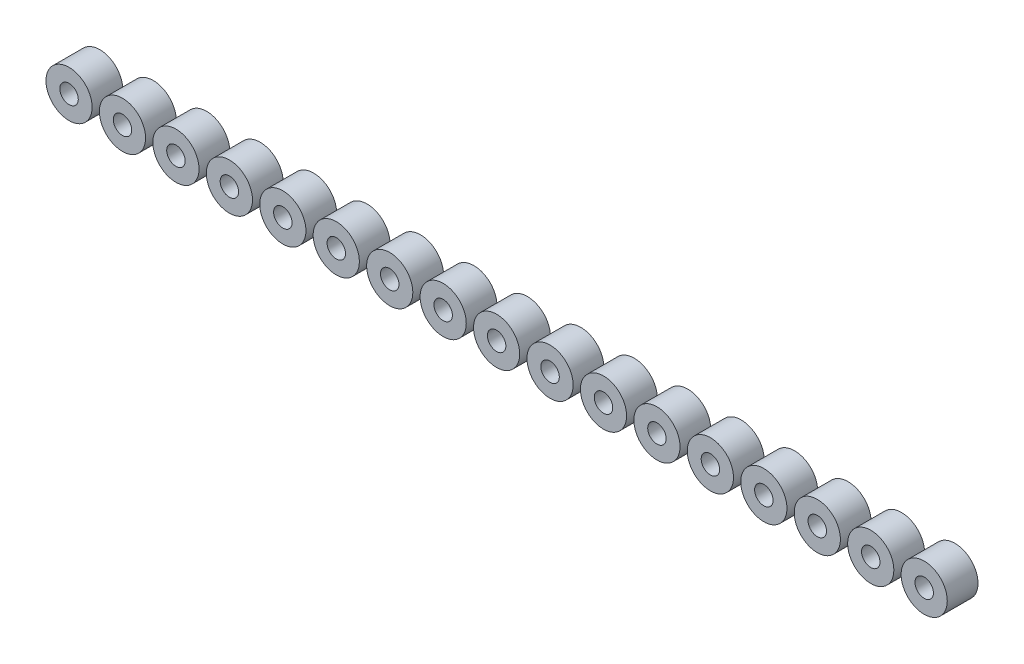
from build123d import *

# Parameters (mm, degrees)
SZKIC1_R                       = 953
SZKIC1_R_2                     = 381
DODANIE_WYCI_GNI_CIE1_DEPTH    = 1268
DODANIE_WYCI_GNI_CIE1_2_DEPTH  = 1268
DODANIE_WYCI_GNI_CIE1_3_DEPTH  = 1268
DODANIE_WYCI_GNI_CIE1_4_DEPTH  = 1268
DODANIE_WYCI_GNI_CIE1_5_DEPTH  = 1268
DODANIE_WYCI_GNI_CIE1_6_DEPTH  = 1268
DODANIE_WYCI_GNI_CIE1_7_DEPTH  = 1268
DODANIE_WYCI_GNI_CIE1_8_DEPTH  = 1268
DODANIE_WYCI_GNI_CIE1_9_DEPTH  = 1268
DODANIE_WYCI_GNI_CIE1_10_DEPTH = 1268
DODANIE_WYCI_GNI_CIE1_11_DEPTH = 1268
DODANIE_WYCI_GNI_CIE1_12_DEPTH = 1268
DODANIE_WYCI_GNI_CIE1_13_DEPTH = 1268
DODANIE_WYCI_GNI_CIE1_14_DEPTH = 1268
DODANIE_WYCI_GNI_CIE1_15_DEPTH = 1268
DODANIE_WYCI_GNI_CIE1_16_DEPTH = 1268
DODANIE_WYCI_GNI_CIE1_17_DEPTH = 1268


with BuildPart() as part:
    # Szkic1 → Dodanie-wyciągnięcie1 (new body)
    with BuildSketch(Plane.XY):
        Circle(SZKIC1_R)
        Circle(SZKIC1_R_2, mode=Mode.SUBTRACT)
    extrude(amount=DODANIE_WYCI_GNI_CIE1_DEPTH)


with BuildPart() as body_2:
    # Szkic1 → Dodanie-wyci_gni_cie1 2 (new body)
    with BuildSketch(Plane.XY):
        with Locations((2206, 0)):
            Circle(SZKIC1_R)
        with Locations((2206, 0)):
            Circle(SZKIC1_R_2, mode=Mode.SUBTRACT)
    extrude(amount=DODANIE_WYCI_GNI_CIE1_2_DEPTH)


with BuildPart() as body_3:
    # Szkic1 → Dodanie-wyci_gni_cie1 3 (new body)
    with BuildSketch(Plane.XY):
        with Locations((4412, 0)):
            Circle(SZKIC1_R)
        with Locations((4412, 0)):
            Circle(SZKIC1_R_2, mode=Mode.SUBTRACT)
    extrude(amount=DODANIE_WYCI_GNI_CIE1_3_DEPTH)


with BuildPart() as body_4:
    # Szkic1 → Dodanie-wyci_gni_cie1 4 (new body)
    with BuildSketch(Plane.XY):
        with Locations((6618, 0)):
            Circle(SZKIC1_R)
        with Locations((6618, 0)):
            Circle(SZKIC1_R_2, mode=Mode.SUBTRACT)
    extrude(amount=DODANIE_WYCI_GNI_CIE1_4_DEPTH)


with BuildPart() as body_5:
    # Szkic1 → Dodanie-wyci_gni_cie1 5 (new body)
    with BuildSketch(Plane.XY):
        with Locations((8824, 0)):
            Circle(SZKIC1_R)
        with Locations((8824, 0)):
            Circle(SZKIC1_R_2, mode=Mode.SUBTRACT)
    extrude(amount=DODANIE_WYCI_GNI_CIE1_5_DEPTH)


with BuildPart() as body_6:
    # Szkic1 → Dodanie-wyci_gni_cie1 6 (new body)
    with BuildSketch(Plane.XY):
        with Locations((11030, 0)):
            Circle(SZKIC1_R)
        with Locations((11030, 0)):
            Circle(SZKIC1_R_2, mode=Mode.SUBTRACT)
    extrude(amount=DODANIE_WYCI_GNI_CIE1_6_DEPTH)


with BuildPart() as body_7:
    # Szkic1 → Dodanie-wyci_gni_cie1 7 (new body)
    with BuildSketch(Plane.XY):
        with Locations((13236, 0)):
            Circle(SZKIC1_R)
        with Locations((13236, 0)):
            Circle(SZKIC1_R_2, mode=Mode.SUBTRACT)
    extrude(amount=DODANIE_WYCI_GNI_CIE1_7_DEPTH)


with BuildPart() as body_8:
    # Szkic1 → Dodanie-wyci_gni_cie1 8 (new body)
    with BuildSketch(Plane.XY):
        with Locations((15442, 0)):
            Circle(SZKIC1_R)
        with Locations((15442, 0)):
            Circle(SZKIC1_R_2, mode=Mode.SUBTRACT)
    extrude(amount=DODANIE_WYCI_GNI_CIE1_8_DEPTH)


with BuildPart() as body_9:
    # Szkic1 → Dodanie-wyci_gni_cie1 9 (new body)
    with BuildSketch(Plane.XY):
        with Locations((17648, 0)):
            Circle(SZKIC1_R)
        with Locations((17648, 0)):
            Circle(SZKIC1_R_2, mode=Mode.SUBTRACT)
    extrude(amount=DODANIE_WYCI_GNI_CIE1_9_DEPTH)


with BuildPart() as body_10:
    # Szkic1 → Dodanie-wyci_gni_cie1 10 (new body)
    with BuildSketch(Plane.XY):
        with Locations((19854, 0)):
            Circle(SZKIC1_R)
        with Locations((19854, 0)):
            Circle(SZKIC1_R_2, mode=Mode.SUBTRACT)
    extrude(amount=DODANIE_WYCI_GNI_CIE1_10_DEPTH)


with BuildPart() as body_11:
    # Szkic1 → Dodanie-wyci_gni_cie1 11 (new body)
    with BuildSketch(Plane.XY):
        with Locations((22060, 0)):
            Circle(SZKIC1_R)
        with Locations((22060, 0)):
            Circle(SZKIC1_R_2, mode=Mode.SUBTRACT)
    extrude(amount=DODANIE_WYCI_GNI_CIE1_11_DEPTH)


with BuildPart() as body_12:
    # Szkic1 → Dodanie-wyci_gni_cie1 12 (new body)
    with BuildSketch(Plane.XY):
        with Locations((24266, 0)):
            Circle(SZKIC1_R)
        with Locations((24266, 0)):
            Circle(SZKIC1_R_2, mode=Mode.SUBTRACT)
    extrude(amount=DODANIE_WYCI_GNI_CIE1_12_DEPTH)


with BuildPart() as body_13:
    # Szkic1 → Dodanie-wyci_gni_cie1 13 (new body)
    with BuildSketch(Plane.XY):
        with Locations((26472, 0)):
            Circle(SZKIC1_R)
        with Locations((26472, 0)):
            Circle(SZKIC1_R_2, mode=Mode.SUBTRACT)
    extrude(amount=DODANIE_WYCI_GNI_CIE1_13_DEPTH)


with BuildPart() as body_14:
    # Szkic1 → Dodanie-wyci_gni_cie1 14 (new body)
    with BuildSketch(Plane.XY):
        with Locations((28678, 0)):
            Circle(SZKIC1_R)
        with Locations((28678, 0)):
            Circle(SZKIC1_R_2, mode=Mode.SUBTRACT)
    extrude(amount=DODANIE_WYCI_GNI_CIE1_14_DEPTH)


with BuildPart() as body_15:
    # Szkic1 → Dodanie-wyci_gni_cie1 15 (new body)
    with BuildSketch(Plane.XY):
        with Locations((30884, 0)):
            Circle(SZKIC1_R)
        with Locations((30884, 0)):
            Circle(SZKIC1_R_2, mode=Mode.SUBTRACT)
    extrude(amount=DODANIE_WYCI_GNI_CIE1_15_DEPTH)


with BuildPart() as body_16:
    # Szkic1 → Dodanie-wyci_gni_cie1 16 (new body)
    with BuildSketch(Plane.XY):
        with Locations((33090, 0)):
            Circle(SZKIC1_R)
        with Locations((33090, 0)):
            Circle(SZKIC1_R_2, mode=Mode.SUBTRACT)
    extrude(amount=DODANIE_WYCI_GNI_CIE1_16_DEPTH)


with BuildPart() as body_17:
    # Szkic1 → Dodanie-wyci_gni_cie1 17 (new body)
    with BuildSketch(Plane.XY):
        with Locations((35296, 0)):
            Circle(SZKIC1_R)
        with Locations((35296, 0)):
            Circle(SZKIC1_R_2, mode=Mode.SUBTRACT)
    extrude(amount=DODANIE_WYCI_GNI_CIE1_17_DEPTH)


solid = Compound([part.part, body_2.part, body_3.part, body_4.part, body_5.part, body_6.part, body_7.part, body_8.part, body_9.part, body_10.part, body_11.part, body_12.part, body_13.part, body_14.part, body_15.part, body_16.part, body_17.part])
